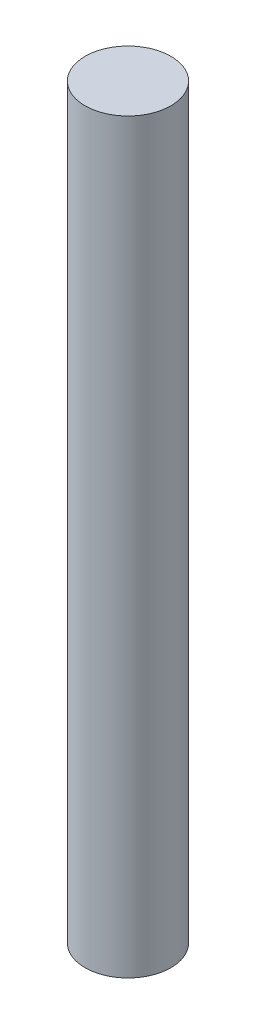
from build123d import *

# Parameters (mm, degrees)
SKETCH1_R           = 2.5
BOSS_EXTRUDE1_DEPTH = 43.5


with BuildPart() as part:
    # Sketch1 → Boss-Extrude1 (new body)
    with BuildSketch(Plane(origin=(0, 0, 0), x_dir=(1, 0, 0), z_dir=(0, 1, 0))):
        Circle(SKETCH1_R)
    extrude(amount=BOSS_EXTRUDE1_DEPTH)


solid = part.part
